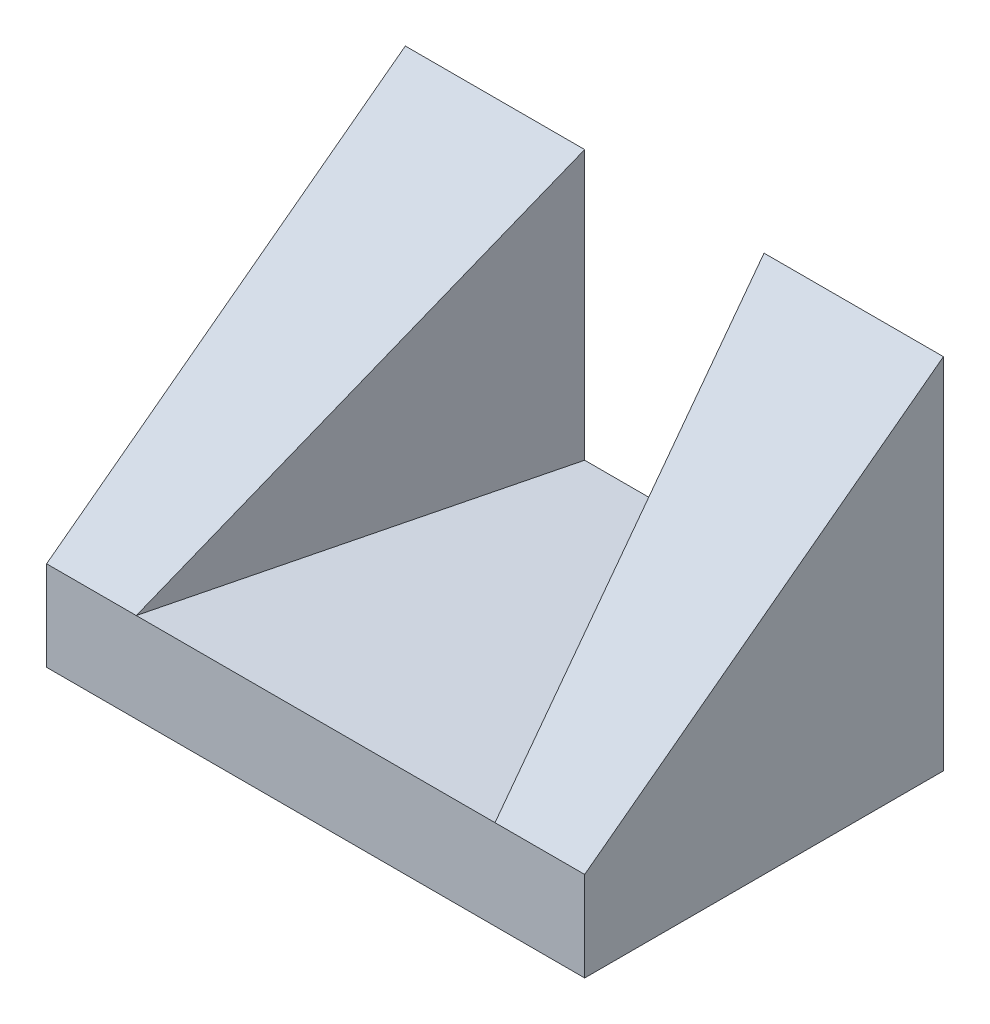
from build123d import *

# Parameters (mm, degrees)
SKETCH_1_W          = 6
SKETCH_1_H          = 4
EXTRUDE_1_DEPTH     = 1
EXTRUDE_2_DEPTH     = 4
CUT_EXTRUDE_1_DEPTH = 9


with BuildPart() as part:
    # 草圖1 → 填料-伸長1 (new body)
    with BuildSketch(Plane(origin=(0, 0, 0), x_dir=(1, 0, 0), z_dir=(0, 1, 0))):
        Rectangle(SKETCH_1_W, SKETCH_1_H)
    extrude(amount=EXTRUDE_1_DEPTH)

    # 草圖1<3> → 填料-伸長2 (add)
    with BuildSketch(Plane(origin=(0, 0, 0), x_dir=(1, 0, 0), z_dir=(0, 1, 0))):
        Polygon((-2, -2), (-1, 2), (-3, 2), (-3, -2), align=None)
        Polygon((3, 2), (1, 2), (2, -2), (3, -2), align=None)
    extrude(amount=EXTRUDE_2_DEPTH)

    # 草圖2 → 除料-伸長1 (cut)
    with BuildSketch(Plane(origin=(3, 0, 0), x_dir=(0, 0, -1), z_dir=(1, 0, 0))):
        Polygon((2, 4), (-2, 1), (-2, 4), align=None)
    extrude(amount=-CUT_EXTRUDE_1_DEPTH, mode=Mode.SUBTRACT)


solid = part.part
